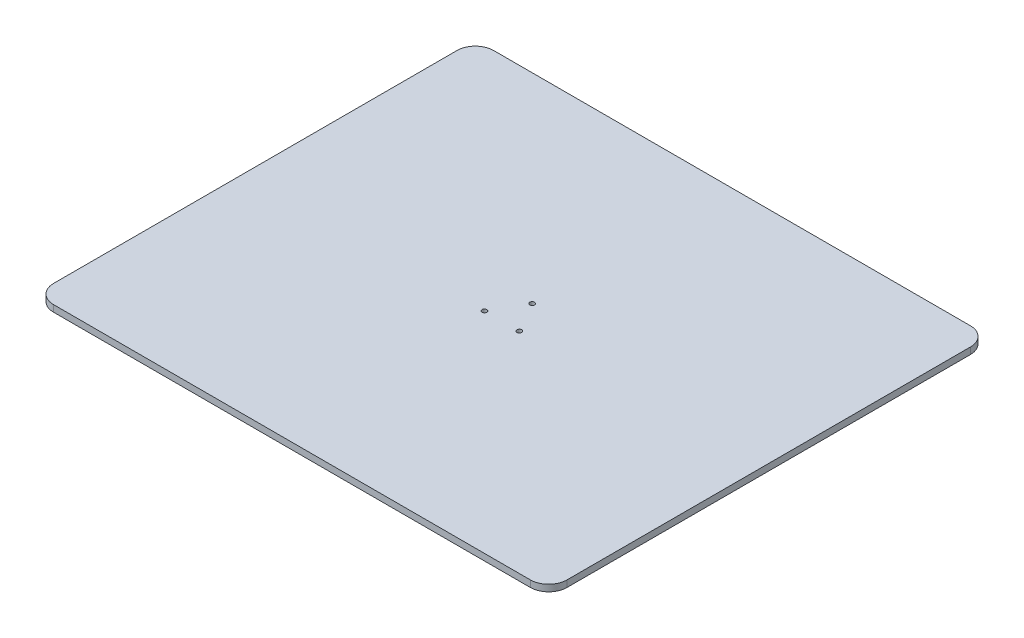
from build123d import *

# Parameters (mm, degrees)
SKETCH1_W           = 1400
SKETCH1_H           = 1200
SKETCH1_R           = 6.5
BOSS_EXTRUDE1_DEPTH = 18
SKETCH2_R           = 5
CUT_EXTRUDE1_DEPTH  = 1
FILLET1_R           = 50
SKETCH4_R           = 75
BOSS_EXTRUDE2_DEPTH = 6


with BuildPart() as part:
    # Sketch1 → Boss-Extrude1 (new body)
    with BuildSketch(Plane(origin=(0, 0, 0), x_dir=(1, 0, 0), z_dir=(0, 1, 0))):
        Rectangle(SKETCH1_W, SKETCH1_H)
        with Locations((0, 55)):
            Circle(SKETCH1_R, mode=Mode.SUBTRACT)
        with Locations((-47.631397208, -27.5)):
            Circle(SKETCH1_R, mode=Mode.SUBTRACT)
        with Locations((47.631397208, -27.5)):
            Circle(SKETCH1_R, mode=Mode.SUBTRACT)
    extrude(amount=BOSS_EXTRUDE1_DEPTH)

    # Sketch2 → Cut-Extrude1 (cut)
    with BuildSketch(Plane.XZ):
        Circle(SKETCH2_R)
    extrude(amount=-CUT_EXTRUDE1_DEPTH, mode=Mode.SUBTRACT)

    # Fillet1
    fillet1_edges = [part.edges().sort_by_distance(p)[0] for p in [
        (700, 9, 600),
        (-700, 9, 600),
        (-700, 9, -600),
        (700, 9, -600),
    ]]
    fillet(fillet1_edges, radius=FILLET1_R)


with BuildPart() as body_2:
    # Sketch4 → Boss-Extrude2 (new body)
    with BuildSketch(Plane(origin=(0, 0, 0), x_dir=(-1, 0, 0), z_dir=(0, -1, 0))):
        Circle(SKETCH4_R)
    extrude(amount=BOSS_EXTRUDE2_DEPTH)


solid = Compound([part.part, body_2.part])
